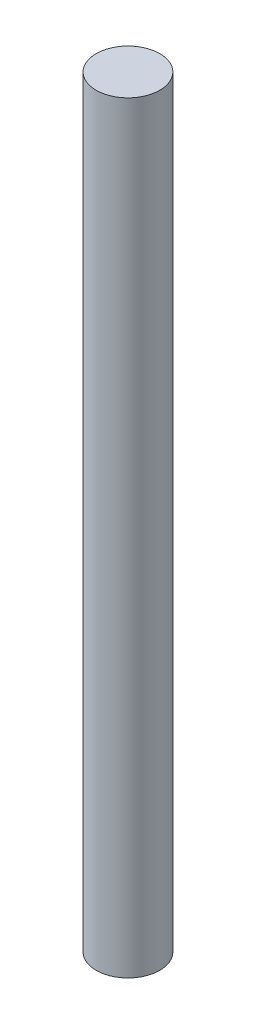
from build123d import *

# Parameters (mm, degrees)
SKETCH1_R      = 1.5875
EXTRUDE1_DEPTH = 38.1


with BuildPart() as part:
    # Sketch1 → Extrude1 (new body)
    with BuildSketch(Plane(origin=(0, 0, 0), x_dir=(1, 0, 0), z_dir=(0, 1, 0))):
        Circle(SKETCH1_R)
    extrude(amount=-EXTRUDE1_DEPTH)


solid = part.part
